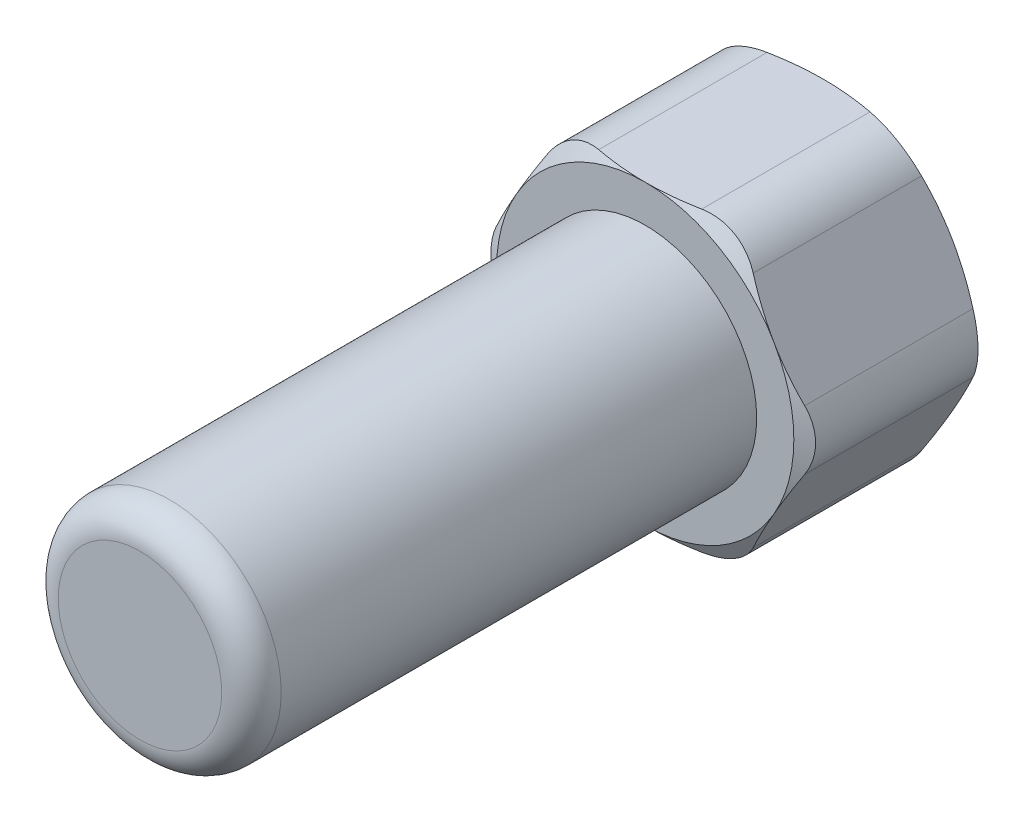
from build123d import *

# Parameters (mm, degrees)
BOSS_EXTRUDE2_DEPTH     = 1.5
SKETCH5_OUTSIDE_W       = 61.376
SKETCH5_OUTSIDE_H       = 60.602
SKETCH5_OUTSIDE_R       = 2.5
CUT_EXTRUDE1_DEPTH      = 15
CUT_EXTRUDE1_DRAFT      = -60
MIRROR1_COPY_1_SKETCH_W = 61.376
MIRROR1_COPY_1_SKETCH_H = 60.602
MIRROR1_COPY_1_SKETCH_R = 2.5
MIRROR1_COPY_1_DEPTH    = 15
MIRROR1_COPY_1_DRAFT    = -60
SKETCH4_3_R             = 1.875
BOSS_EXTRUDE3_DEPTH     = 10
FILLET1_R               = 1
FILLET2_R               = 0.5


with BuildPart() as part:
    # Sketch4 → Boss-Extrude2 (new, symmetric)
    with BuildSketch(Plane.XY):
        Polygon((1.443375673, 2.5), (-1.443375673, 2.5), (-2.886751346, 0), (-1.443375673, -2.5), (1.443375673, -2.5), (2.886751346, 0), align=None)
    extrude(amount=BOSS_EXTRUDE2_DEPTH, both=True)


with BuildPart() as cut_extrude1_tool:
    # Sketch5 outside → Cut-Extrude1 (with draft: the straight prism first)
    with BuildSketch(Plane.XY.offset(1.5)):
        Rectangle(SKETCH5_OUTSIDE_W, SKETCH5_OUTSIDE_H)
        Circle(SKETCH5_OUTSIDE_R, mode=Mode.SUBTRACT)
    extrude(amount=-CUT_EXTRUDE1_DEPTH)
    # Cut-Extrude1: the draft: its side faces are tilted about the plane it starts from
    cut_extrude1_sides = [cut_extrude1_tool.faces().sort_by_distance(p)[0] for p in [
        (0, -30.301, -6),
        (30.688, 0, -6),
        (0, 30.301, -6),
        (-30.688, 0, -6),
        (-2.5, 0, -6),
    ]]
    draft(cut_extrude1_sides, Plane.XY.offset(1.5), CUT_EXTRUDE1_DRAFT)


with BuildPart() as part_1:
    add(part.part)

    # Cut-Extrude1: cut by cut_extrude1_tool
    add(cut_extrude1_tool.part, mode=Mode.SUBTRACT)


with BuildPart() as mirror1_copy_1_tool:
    # Mirror1 copy 1 sketch → Mirror1 copy 1 (with draft: the straight prism first)
    with BuildSketch(Plane(origin=(0, 0, -1.5), x_dir=(1, 0, 0), z_dir=(0, 0, -1))):
        Rectangle(MIRROR1_COPY_1_SKETCH_W, MIRROR1_COPY_1_SKETCH_H)
        Circle(MIRROR1_COPY_1_SKETCH_R, mode=Mode.SUBTRACT)
    extrude(amount=-MIRROR1_COPY_1_DEPTH)
    # Mirror1 copy 1: the draft: its side faces are tilted about the plane it starts from
    mirror1_copy_1_sides = [mirror1_copy_1_tool.faces().sort_by_distance(p)[0] for p in [
        (0, -30.301, 6),
        (30.688, 0, 6),
        (0, 30.301, 6),
        (-30.688, 0, 6),
        (-2.5, 0, 6),
    ]]
    draft(mirror1_copy_1_sides, Plane(origin=(0, 0, -1.5), x_dir=(1, 0, 0), z_dir=(0, 0, -1)), MIRROR1_COPY_1_DRAFT)


with BuildPart() as part_2:
    add(part_1.part)

    # Mirror1 copy 1: cut by mirror1_copy_1_tool
    add(mirror1_copy_1_tool.part, mode=Mode.SUBTRACT)

    # Sketch4_3 → Boss-Extrude3 (add)
    with BuildSketch(Plane.XY):
        Circle(SKETCH4_3_R)
    extrude(amount=BOSS_EXTRUDE3_DEPTH)

    # Fillet1
    fillet1_edges = [part_2.edges().sort_by_distance(p)[0] for p in [
        (2.886751346, 0, 0),
        (1.443375673, -2.5, 0),
        (-1.443375673, -2.5, 0),
        (-2.886751346, 0, 0),
        (-1.443375673, 2.5, 0),
        (1.443375673, 2.5, 0),
    ]]
    fillet(fillet1_edges, radius=FILLET1_R)

    # Fillet2
    fillet2_edges = [part_2.edges().sort_by_distance(p)[0] for p in [
        (-1.875, 0, 10),
    ]]
    fillet(fillet2_edges, radius=FILLET2_R)


solid = part_2.part
